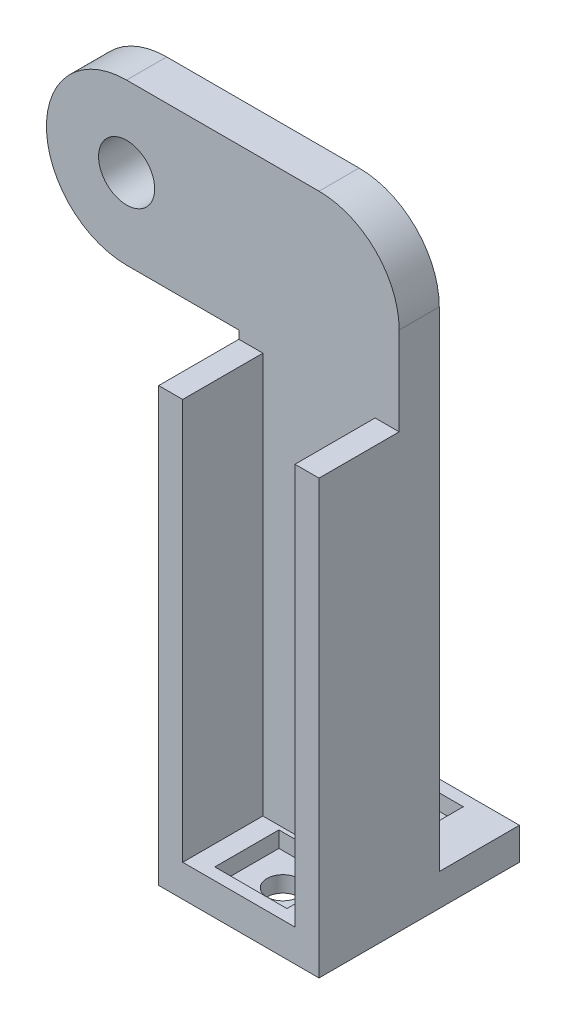
from build123d import *

# Parameters (mm, degrees)
SKETCH1_R          = 1.75
AXLEHOLDER_DEPTH   = 2.5
SKETCH1_3_W        = 10
SKETCH1_3_H        = 2
BASE_DEPTH         = 7.5
BASE_DEPTH_BACK    = 5
SKETCH2_R          = 1
BOLTHOLES_DEPTH    = 3
SKETCH3_W          = 4.5
SKETCH3_H          = 4
NUTSLOTS_DEPTH     = 1
SKETCH4_W          = 1.5
SKETCH4_H          = 5
STIFFENERRIB_DEPTH = 25


with BuildPart() as part:
    # Sketch1 → AxleHolder (new body)
    with BuildSketch(Plane.XY):
        with BuildLine():
            Line((-12, 27.5), (-5, 27.5))
            Line((-5, 27.5), (-5, 0))
            Line((-5, 0), (5, 0))
            Line((5, 0), (5, 32.5))
            ThreePointArc((5, 32.5), (3.535533906, 36.035533906), (0, 37.5))
            Line((0, 37.5), (-12, 37.5))
            ThreePointArc((-12, 37.5), (-17, 32.5), (-12, 27.5))
        make_face()
        with Locations((-12, 32.5)):
            Circle(SKETCH1_R, mode=Mode.SUBTRACT)
    extrude(amount=AXLEHOLDER_DEPTH)

    # Sketch1_3 → Base (add, two sides)
    with BuildSketch(Plane.XY) as base_sk:
        with Locations((0, 1)):
            Rectangle(SKETCH1_3_W, SKETCH1_3_H)
    extrude(amount=BASE_DEPTH)
    extrude(base_sk.sketch, amount=-BASE_DEPTH_BACK)

    # Sketch2 → BoltHoles (cut, through all)
    with BuildSketch(Plane(origin=(0, 2, 0), x_dir=(1, 0, 0), z_dir=(0, 1, 0))):
        with Locations((0, 2.25)):
            Circle(SKETCH2_R)
        with Locations((0, -4.75)):
            Circle(SKETCH2_R)
    extrude(amount=-BOLTHOLES_DEPTH, mode=Mode.SUBTRACT)

    # Sketch3 → NutSlots (cut)
    with BuildSketch(Plane(origin=(0, 2, 0), x_dir=(1, 0, 0), z_dir=(0, 1, 0))):
        with Locations((0, -4.75)):
            Rectangle(SKETCH3_W, SKETCH3_H)
        with Locations((0, 2.25)):
            Rectangle(SKETCH3_W, SKETCH3_H)
    extrude(amount=-NUTSLOTS_DEPTH, mode=Mode.SUBTRACT)

    # Sketch4 → StiffenerRib (add)
    with BuildSketch(Plane(origin=(0, 2, 0), x_dir=(1, 0, 0), z_dir=(0, 1, 0))):
        with Locations((-4.25, -5)):
            Rectangle(SKETCH4_W, SKETCH4_H)
    stiffenerrib = extrude(amount=STIFFENERRIB_DEPTH)

    # StiffenerRib2: StiffenerRib across plane
    add(stiffenerrib.mirror(Plane(origin=(0, 0, 0), x_dir=(0, 0, 1), z_dir=(1, 0, 0))))


solid = part.part
